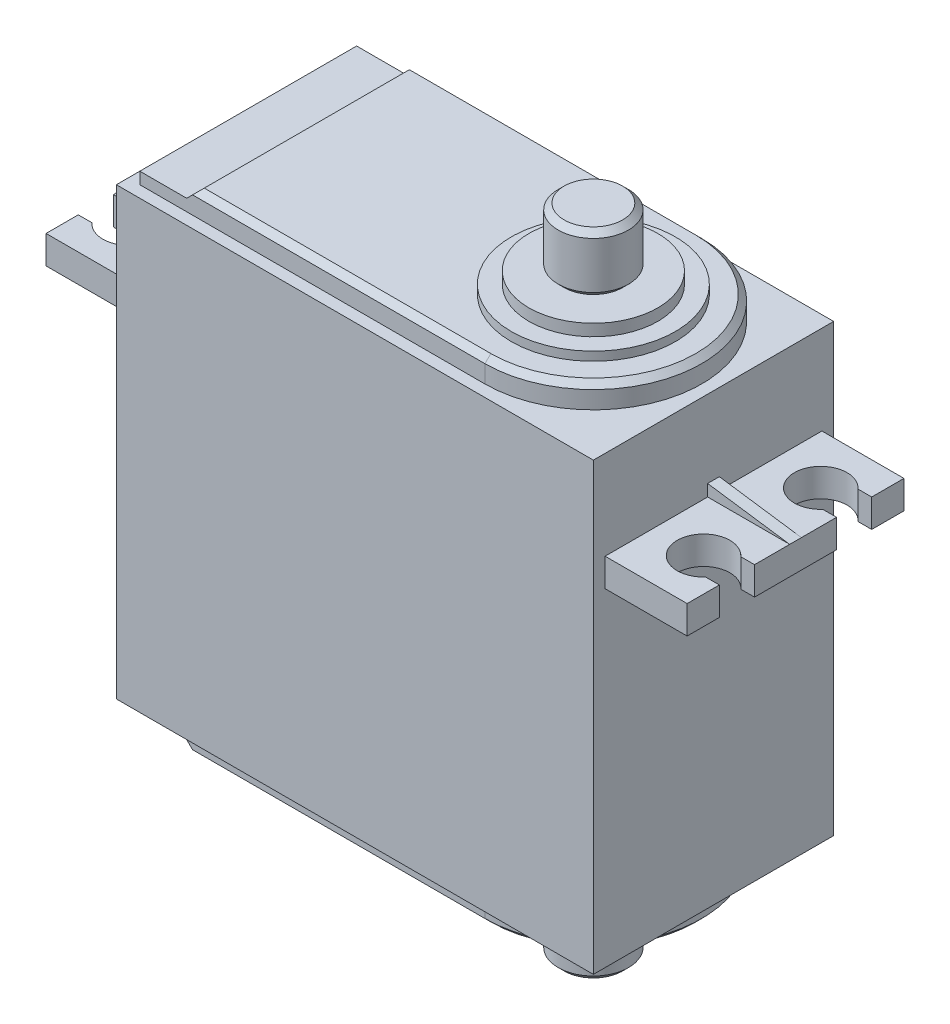
from build123d import *

# Parameters (mm, degrees)
CROQUIS1_W               = 40.7
CROQUIS1_H               = 38
SALIENTE_EXTRUIR1_DEPTH  = 10.25
CROQUIS2_W               = 7
CROQUIS2_H               = 2.4
SALIENTE_EXTRUIR2_DEPTH  = 18.5
SALIENTE_EXTRUIR3_DEPTH  = 0.5
CORTAR_EXTRUIR1_DEPTH    = 2.4
SALIENTE_EXTRUIR4_DEPTH  = 2
CORTAR_EXTRUIR3_START    = -18.5
CORTAR_EXTRUIR3_DEPTH    = 18.5
CROQUIS10_R              = 7
SALIENTE_EXTRUIR5_DEPTH  = 0.75
CROQUIS11_R              = 5.5
SALIENTE_EXTRUIR6_DEPTH  = 1
CROQUIS12_R              = 3
SALIENTE_EXTRUIR7_DEPTH  = 5
CHAFL_N2_SIZE            = 0.5
CHAFL_N2_OF_MIRROR1_SIZE = 0.5


with BuildPart() as part:
    # Croquis1 → Saliente-Extruir1 (new body, symmetric)
    with BuildSketch(Plane.XY):
        Rectangle(CROQUIS1_W, CROQUIS1_H)
    extrude(amount=SALIENTE_EXTRUIR1_DEPTH, both=True)

    # Croquis2 → Saliente-Extruir2 (add)
    with BuildSketch(Plane.XY.offset(9.25)):
        with Locations((-23.85, 10.2)):
            Rectangle(CROQUIS2_W, CROQUIS2_H)
        with Locations((23.85, 10.2)):
            Rectangle(CROQUIS2_W, CROQUIS2_H)
    extrude(amount=-SALIENTE_EXTRUIR2_DEPTH)

    # Croquis3 → Saliente-Extruir3 (add, symmetric)
    with BuildSketch(Plane.XY):
        Polygon((-20.35, 12.4), (-20.35, 11.4), (-27.35, 11.4), align=None)
        Polygon((20.35, 12.4), (27.35, 11.4), (20.35, 11.4), align=None)
    extrude(amount=SALIENTE_EXTRUIR3_DEPTH, both=True)

    # Croquis4 → Cortar-Extruir1 (cut)
    with BuildSketch(Plane(origin=(0, 11.4, 0), x_dir=(1, 0, 0), z_dir=(0, 1, 0))):
        with BuildLine():
            Line((-27.35, 6.5), (-26.177050983, 6.5))
            ThreePointArc((-26.177050983, 6.5), (-22.25, 5), (-26.177050983, 3.5))
            Line((-26.177050983, 3.5), (-27.35, 3.5))
            Line((-27.35, 3.5), (-27.35, 6.5))
        make_face()
        with BuildLine():
            Line((-27.35, -3.5), (-26.177050983, -3.5))
            ThreePointArc((-26.177050983, -3.5), (-22.25, -5), (-26.177050983, -6.5))
            Line((-26.177050983, -6.5), (-27.35, -6.5))
            Line((-27.35, -6.5), (-27.35, -3.5))
        make_face()
        with BuildLine():
            Line((26.177050983, -6.5), (27.35, -6.5))
            Line((27.35, -6.5), (27.35, -3.5))
            Line((27.35, -3.5), (26.177050983, -3.5))
            ThreePointArc((26.177050983, -3.5), (22.25, -5), (26.177050983, -6.5))
        make_face()
        with BuildLine():
            Line((27.35, 3.5), (26.177050983, 3.5))
            ThreePointArc((26.177050983, 3.5), (22.25, 5), (26.177050983, 6.5))
            Line((26.177050983, 6.5), (27.35, 6.5))
            Line((27.35, 6.5), (27.35, 3.5))
        make_face()
    extrude(amount=-CORTAR_EXTRUIR1_DEPTH, mode=Mode.SUBTRACT)

    # Croquis6 → Saliente-Extruir4 (add)
    with BuildSketch(Plane(origin=(0, 19, 0), x_dir=(1, 0, 0), z_dir=(0, 1, 0))):
        with BuildLine():
            Line((10.1, 9.25), (-19.35, 9.25))
            Line((-19.35, 9.25), (-19.35, -9.25))
            Line((-19.35, -9.25), (10.1, -9.25))
            ThreePointArc((10.1, -9.25), (19.35, 0), (10.1, 9.25))
        make_face()
    saliente_extruir4 = extrude(amount=SALIENTE_EXTRUIR4_DEPTH)

    # Croquis9 → Cortar-Extruir3 (cut)
    with BuildSketch(Plane.XY.offset(9.25).offset(CORTAR_EXTRUIR3_START)):
        Polygon((-19.35, 21), (-19.35, 20), (-15.35, 20), (-14.35, 21), align=None)
    cortar_extruir3 = extrude(amount=CORTAR_EXTRUIR3_DEPTH, mode=Mode.SUBTRACT)

    # Croquis10 → Saliente-Extruir5 (add)
    with BuildSketch(Plane(origin=(0, 21, 0), x_dir=(1, 0, 0), z_dir=(0, 1, 0))):
        with Locations((10.1, 0)):
            Circle(CROQUIS10_R)
    saliente_extruir5 = extrude(amount=SALIENTE_EXTRUIR5_DEPTH)

    # Croquis11 → Saliente-Extruir6 (add)
    with BuildSketch(Plane(origin=(0, 21.75, 0), x_dir=(1, 0, 0), z_dir=(0, 1, 0))):
        with Locations((10.1, 0)):
            Circle(CROQUIS11_R)
    saliente_extruir6 = extrude(amount=SALIENTE_EXTRUIR6_DEPTH)

    # Croquis12 → Saliente-Extruir7 (add)
    with BuildSketch(Plane(origin=(0, 22.75, 0), x_dir=(1, 0, 0), z_dir=(0, 1, 0))):
        with Locations((10.1, 0)):
            Circle(CROQUIS12_R)
    saliente_extruir7 = extrude(amount=SALIENTE_EXTRUIR7_DEPTH)

    # Chaflán2
    chafl_n2_edges = [part.edges().sort_by_distance(p)[0] for p in [
        (19.35, 21, 0),
        (-2.125, 21, -9.25),
        (-2.125, 21, 9.25),
        (7.1, 27.75, 0),
    ]]
    chamfer(chafl_n2_edges, length=CHAFL_N2_SIZE)

    # Croquis13 → Cortar-Revolución1 (revolve, cut)
    with BuildSketch(Plane.XY):
        Polygon((7.1, 23.25), (7.1, 22.75), (7.6, 22.75), align=None)
    revolve(axis=Axis((10.1, 27.75, 0), (0, -1, 0)), mode=Mode.SUBTRACT)

    # Mirror1: Saliente-Extruir4, Cortar-Extruir3, Saliente-Extruir5, Saliente-Extruir6, Saliente-Extruir7 across plane
    add(saliente_extruir4.mirror(Plane.ZX))
    add(cortar_extruir3.mirror(Plane.ZX), mode=Mode.SUBTRACT)
    add(saliente_extruir5.mirror(Plane.ZX))
    add(saliente_extruir6.mirror(Plane.ZX))
    add(saliente_extruir7.mirror(Plane.ZX))

    # Chaflán2 of Mirror1
    chafl_n2_of_mirror1_edges = [part.edges().sort_by_distance(p)[0] for p in [
        (19.35, -21, 0),
        (-2.125, -21, -9.25),
        (-2.125, -21, 9.25),
        (7.1, -27.75, 0),
    ]]
    chamfer(chafl_n2_of_mirror1_edges, length=CHAFL_N2_OF_MIRROR1_SIZE)


solid = part.part
